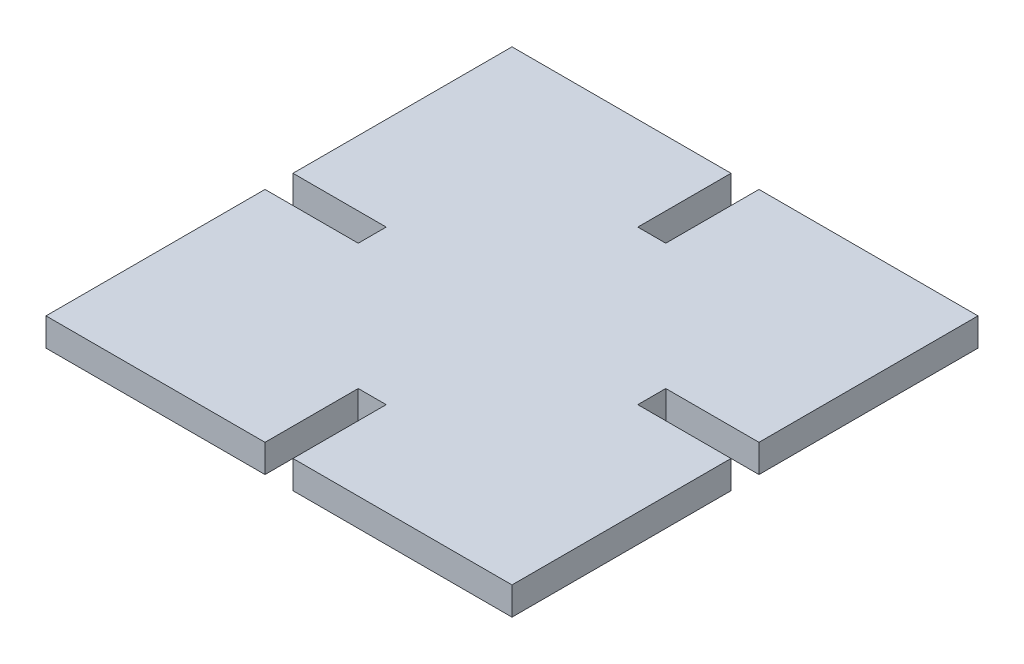
from build123d import *

# Parameters (mm, degrees)
BOSS_EXTRUDE1_DEPTH = 3


with BuildPart() as part:
    # Sketch1 → Boss-Extrude1 (new body)
    with BuildSketch(Plane(origin=(0, 0, 0), x_dir=(1, 0, 0), z_dir=(0, 1, 0))):
        Polygon((-1.5, 25), (-1.5, 15), (1.5, 15), (1.5, 25), (25, 25), (25, 1.5), (15, 1.5), (15, -1.5), (25, -1.5), (25, -25), (1.5, -25), (1.5, -15), (-1.5, -15), (-1.5, -25), (-25, -25), (-25, -1.5), (-15, -1.5), (-15, 1.5), (-25, 1.5), (-25, 25), align=None)
    extrude(amount=BOSS_EXTRUDE1_DEPTH)


solid = part.part
